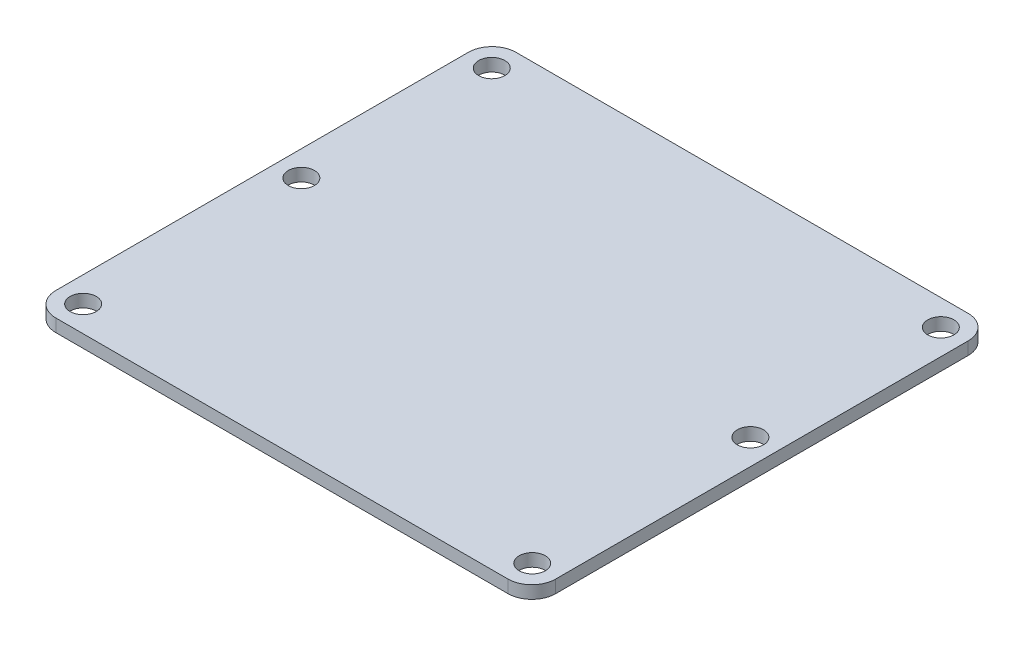
from build123d import *

# Parameters (mm, degrees)
SKETCH_1_W          = 63
SKETCH_1_H          = 58
EXTRUDE_1_DEPTH     = 1.6
SKETCH_2_R          = 1.65
CUT_EXTRUDE_1_DEPTH = 1.6
FILLET_1_R          = 3
SKETCH_3_R          = 1.65
CUT_EXTRUDE_2_DEPTH = 1.6


with BuildPart() as part:
    # 草图1 → 凸台-拉伸1 (new body)
    with BuildSketch(Plane(origin=(0, 0, 0), x_dir=(1, 0, 0), z_dir=(0, 1, 0))):
        Rectangle(SKETCH_1_W, SKETCH_1_H)
    extrude(amount=EXTRUDE_1_DEPTH)

    # 草图2 → 切除-拉伸1 (cut)
    with BuildSketch(Plane(origin=(0, 1.6, 0), x_dir=(1, 0, 0), z_dir=(0, 1, 0))):
        with Locations((-28.3, 25.75)):
            Circle(SKETCH_2_R)
        with Locations((28.3, 25.75)):
            Circle(SKETCH_2_R)
        with Locations((28.3, -25.75)):
            Circle(SKETCH_2_R)
        with Locations((-28.3, -25.75)):
            Circle(SKETCH_2_R)
    extrude(amount=-CUT_EXTRUDE_1_DEPTH, mode=Mode.SUBTRACT)

    # 圆角1
    fillet_1_edges = [part.edges().sort_by_distance(p)[0] for p in [
        (31.5, 0.8, 29),
        (-31.5, 0.8, 29),
        (-31.5, 0.8, -29),
        (31.5, 0.8, -29),
    ]]
    fillet(fillet_1_edges, radius=FILLET_1_R)

    # 草图3 → 切除-拉伸2 (cut)
    with BuildSketch(Plane(origin=(0, 1.6, 0), x_dir=(1, 0, 0), z_dir=(0, 1, 0))):
        with Locations((-28.3, 1.75)):
            Circle(SKETCH_3_R)
        with Locations((28.3, 1.75)):
            Circle(SKETCH_3_R)
    extrude(amount=-CUT_EXTRUDE_2_DEPTH, mode=Mode.SUBTRACT)


solid = part.part
